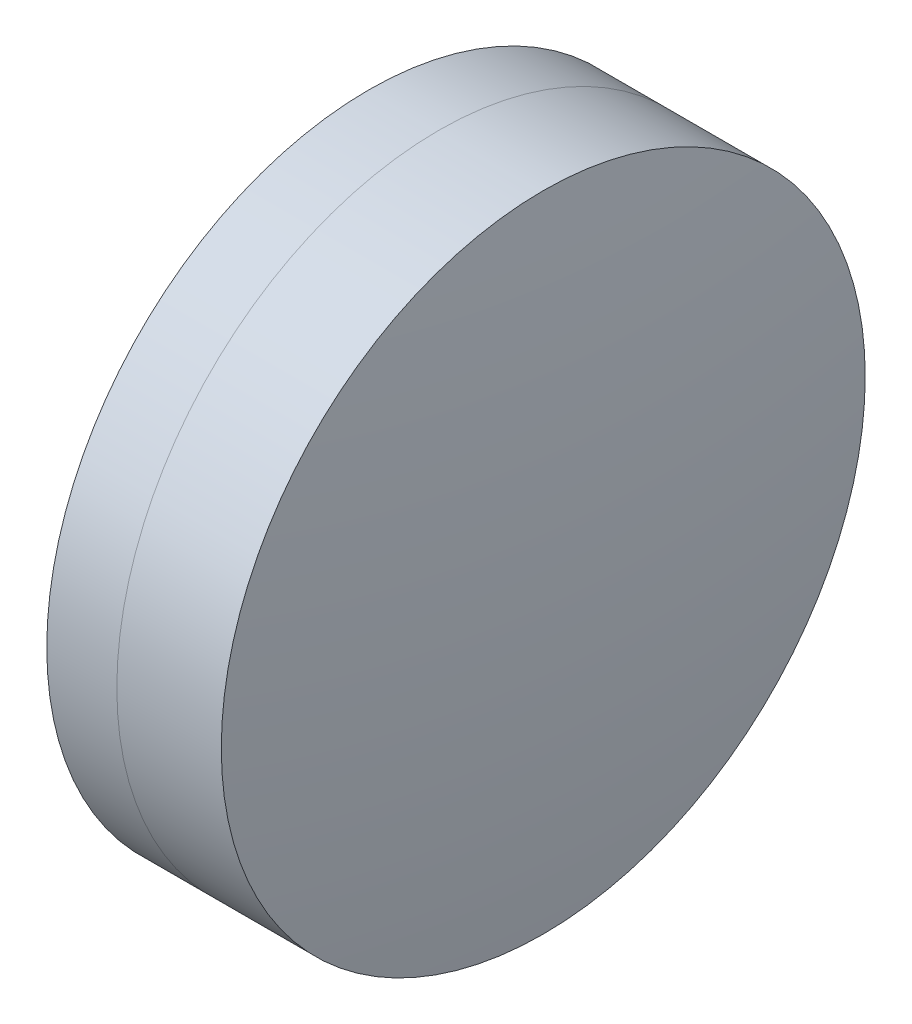
from build123d import *


with BuildPart() as part:
    # 草图1 one side → 旋转1 (revolve)
    with BuildSketch(Plane(origin=(0, 0, 0), x_dir=(1, 0, 0), z_dir=(0, 1, 0)), mode=Mode.PRIVATE) as revolve_1_sk:
        with BuildLine():
            ThreePointArc((239.76375442, 12.7), (238.439943637, 6.411230398), (237.995845808, 0))
            Line((237.995845808, 0), (244.995845808, 0))
            ThreePointArc((244.995845808, 0), (244.372921252, 6.468867745), (242.527040504, 12.7))
            Line((242.527040504, 12.7), (239.76375442, 12.7))
        make_face()
    revolve(revolve_1_sk.sketch.rotate(Axis((161.833171693, 0, 0), (1, 0, 0)), 180), axis=Axis((161.833171693, 0, 0), (1, 0, 0)))  # turned: the seam where the file's is


with BuildPart() as body_2:
    # 草图2 one side → 旋转3 (revolve)
    with BuildSketch(Plane(origin=(0, 0, 0), x_dir=(1, 0, 0), z_dir=(0, 1, 0)), mode=Mode.PRIVATE) as revolve_3_sk:
        with BuildLine():
            Line((246.647628676, 12.7), (242.527040504, 12.7))
            ThreePointArc((242.527040504, 12.7), (244.372921252, 6.468867745), (244.995845808, 0))
            Line((244.995845808, 0), (247.495845808, 0))
            ThreePointArc((247.495845808, 0), (247.283555572, 6.364147082), (246.647628676, 12.7))
        make_face()
    revolve(revolve_3_sk.sketch.rotate(Axis((-0.551919993, 0, 0), (1, 0, 0)), 180), axis=Axis((-0.551919993, 0, 0), (1, 0, 0)))  # turned: the seam where the file's is


solid = Compound([part.part, body_2.part])
